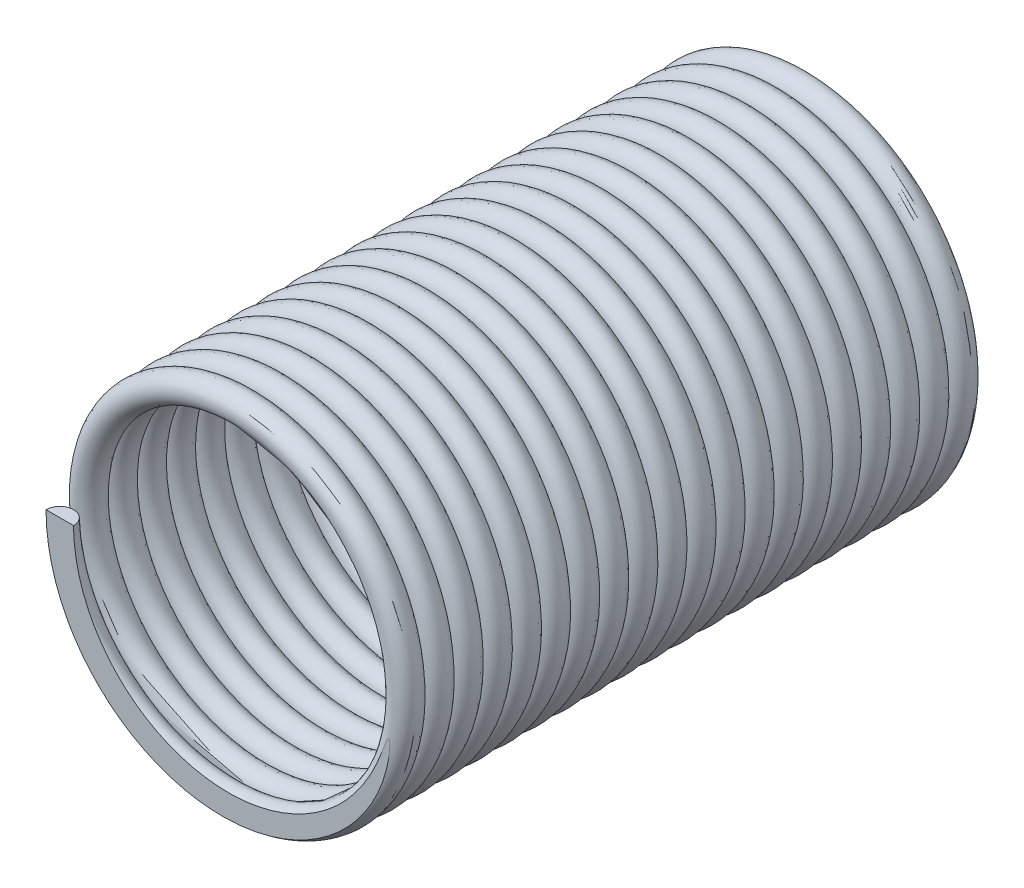
from build123d import *

# Parameters (mm, degrees)
SWEEP4_PITCH       = 2.10875
SWEEP4_HEIGHT      = 42.175
SWEEP4_RADIUS      = 12
SWEEP4_START_ANGLE = -180
SKETCH8_R          = 1
SKETCH9_W          = 26.838295111
SKETCH9_H          = 28.488190302
CUT_EXTRUDE2_DEPTH = 10
SKETCH10_W         = 30.358071519
SKETCH10_H         = 33.437875876
CUT_EXTRUDE3_DEPTH = 10


with BuildPart() as part:
    # Sweep4: sweep along a helix
    with BuildLine() as sweep4_path:
        add(Helix(SWEEP4_PITCH, SWEEP4_HEIGHT, SWEEP4_RADIUS, center=(12, 0, 0), direction=(0, 0, 1), lefthand=True, mode=Mode.PRIVATE).rotate(Axis((12, 0, 0), (0, 0, 1)), SWEEP4_START_ANGLE))
    # Sketch8 → Sweep4 (sweep)
    with BuildSketch(Plane(origin=(0, 0, 0), x_dir=(1, 0, 0), z_dir=(0, 1, 0))):
        Circle(SKETCH8_R)
    sweep(path=sweep4_path.line, is_frenet=True)

    # Sketch9 → Cut-Extrude2 (cut)
    with BuildSketch(Plane.XY.offset(-10)):
        with Locations((12.054996507, 0)):
            Rectangle(SKETCH9_W, SKETCH9_H)
    extrude(amount=CUT_EXTRUDE2_DEPTH, mode=Mode.SUBTRACT)

    # Sketch10 → Cut-Extrude3 (cut)
    with BuildSketch(Plane.XY.offset(52.175)):
        with Locations((12.054996507, 0)):
            Rectangle(SKETCH10_W, SKETCH10_H)
    extrude(amount=-CUT_EXTRUDE3_DEPTH, mode=Mode.SUBTRACT)


solid = part.part
